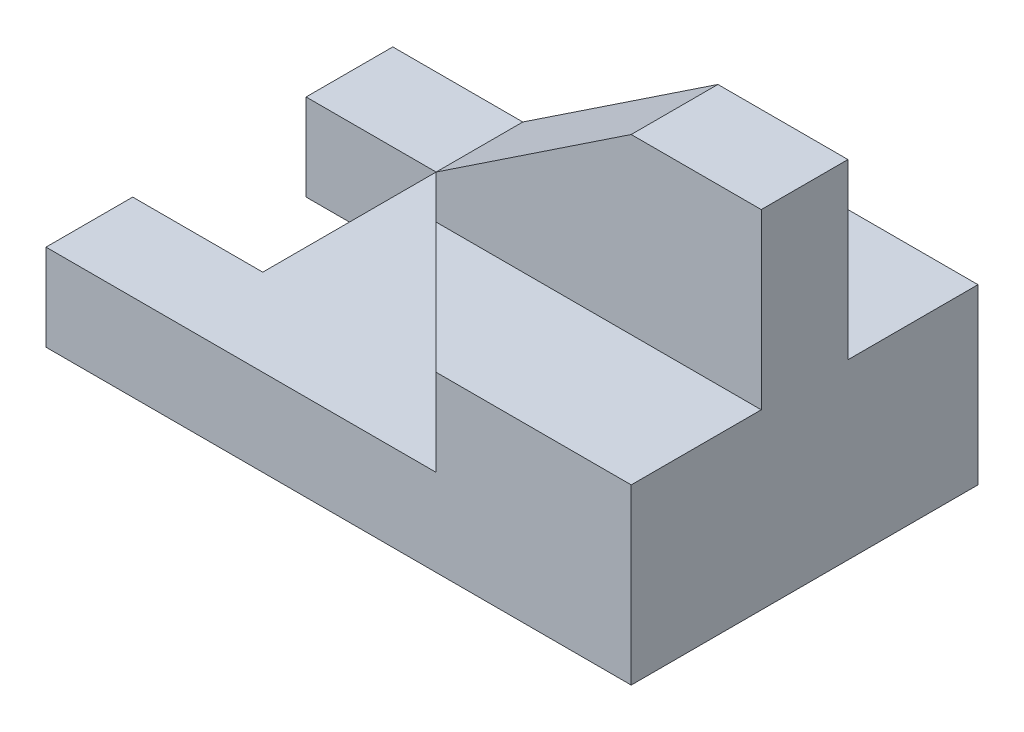
from build123d import *

# Parameters (mm, degrees)
BOSS_EXTRUDE1_DEPTH = 2
BOSS_EXTRUDE2_DEPTH = 2
BOSS_EXTRUDE3_DEPTH = 1


with BuildPart() as part:
    # Sketch2 → Boss-Extrude1 (new body)
    with BuildSketch(Plane(origin=(0, 0, 0), x_dir=(1, 0, 0), z_dir=(0, 1, 0))):
        Polygon((-6.75, -2), (-6.75, -4), (6.75, -4), (6.75, 4), (-6.75, 4), (-6.75, 2), (-3.75, 2), (-3.75, -2), align=None)
    extrude(amount=BOSS_EXTRUDE1_DEPTH)

    # Sketch3 → Boss-Extrude2 (add)
    with BuildSketch(Plane(origin=(0, 2, 0), x_dir=(1, 0, 0), z_dir=(0, 1, 0))):
        Polygon((6.75, 4), (2.25, 4), (-0.75, 1), (-0.75, -1), (2.25, -4), (6.75, -4), align=None)
    extrude(amount=BOSS_EXTRUDE2_DEPTH)

    # Sketch5 → Boss-Extrude3 (add, symmetric)
    with BuildSketch(Plane.XY):
        Polygon((3.75, 8), (6.75, 8), (6.75, 4), (-0.75, 4), (-0.75, 5), align=None)
    extrude(amount=BOSS_EXTRUDE3_DEPTH, both=True)


solid = part.part
